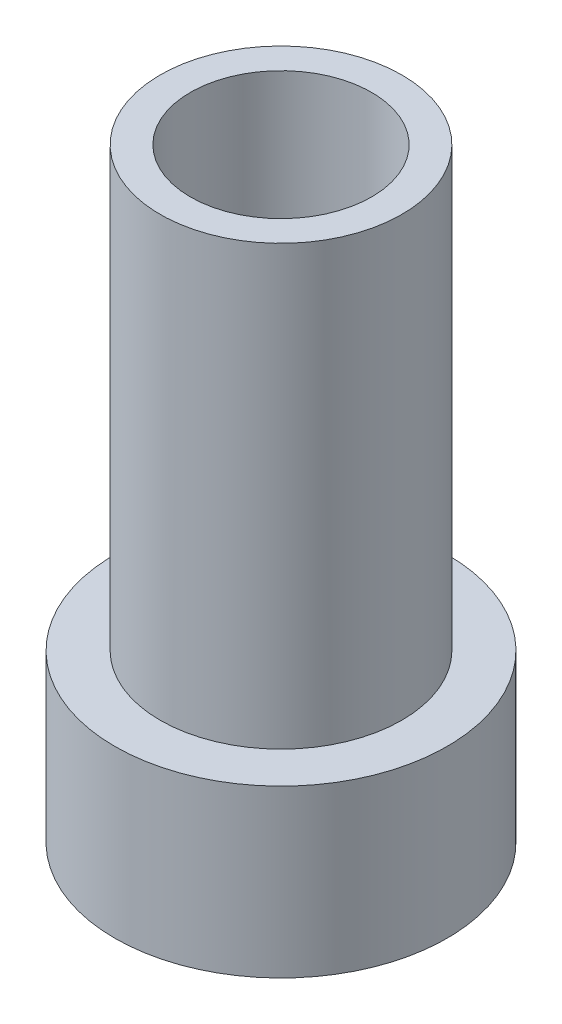
from build123d import *

# Parameters (mm, degrees)
SKETCH_2_R          = 3
CUT_EXTRUDE_1_DEPTH = 10
SKETCH_3_R          = 2
CUT_EXTRUDE_2_DEPTH = 21
SKETCH_4_R          = 5.5
SKETCH_4_R_2        = 4
CUT_EXTRUDE_3_DEPTH = 5.5


with BuildPart() as part:
    # Эскиз1 → Повернуть1 (revolve)
    with BuildSketch(Plane.XY):
        Polygon((4, 20), (4, 11), (5.5, 11), (5.5, 0), (0, 0), (0, 20), align=None)
    revolve(axis=Axis((0, 0, 0), (0, 1, 0)))

    # Эскиз2 → Вырез-Вытянуть1 (cut)
    with BuildSketch(Plane(origin=(0, 20, 0), x_dir=(1, 0, 0), z_dir=(0, 1, 0))):
        Circle(SKETCH_2_R)
    extrude(amount=-CUT_EXTRUDE_1_DEPTH, mode=Mode.SUBTRACT)

    # Эскиз3 → Вырез-Вытянуть2 (cut, through all)
    with BuildSketch(Plane.XZ):
        Circle(SKETCH_3_R)
    extrude(amount=-CUT_EXTRUDE_2_DEPTH, mode=Mode.SUBTRACT)

    # Эскиз4 → Вырез-Вытянуть3 (cut)
    with BuildSketch(Plane(origin=(0, 11, 0), x_dir=(1, 0, 0), z_dir=(0, 1, 0))):
        Circle(SKETCH_4_R)
        Circle(SKETCH_4_R_2, mode=Mode.SUBTRACT)
    extrude(amount=-CUT_EXTRUDE_3_DEPTH, mode=Mode.SUBTRACT)


solid = part.part
